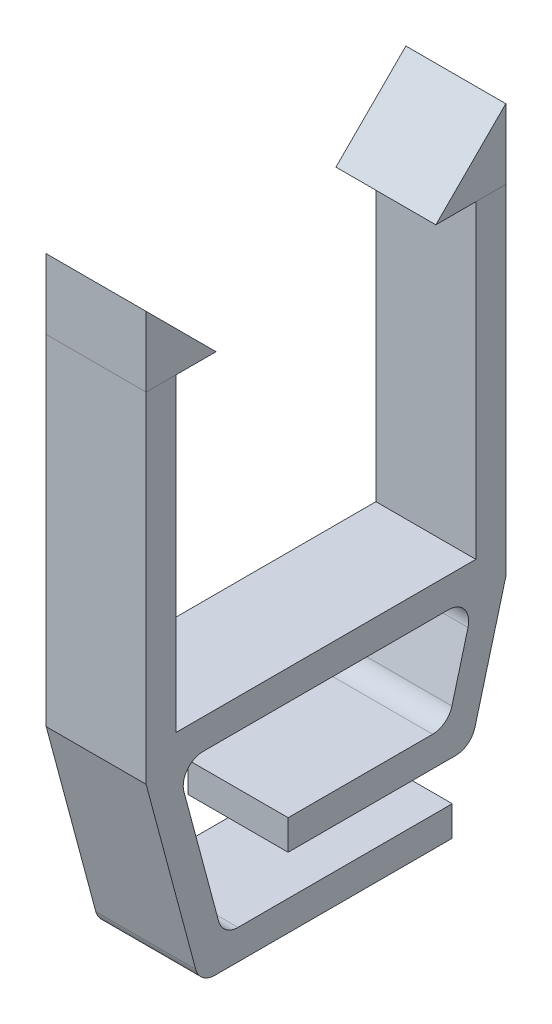
from build123d import *

# Parameters (mm, degrees)
SKETCH_1_W        = 5
SKETCH_1_H        = 1.5
EXTRUDE_1_DEPTH   = 15.5
EXTRUDE_1_2_DEPTH = 15.5
SKETCH_2_W        = 5
SKETCH_2_H        = 18
EXTRUDE_2_DEPTH   = 1.5
EXTRUDE_3_DEPTH   = 5
EXTRUDE_3_2_DEPTH = 5
EXTRUDE_4_DEPTH   = 5
FILLET_1_R        = 1


with BuildPart() as part:
    # 草图1 → 凸台-拉伸1 (new body)
    with BuildSketch(Plane(origin=(0, 0, 0), x_dir=(1, 0, 0), z_dir=(0, 1, 0))):
        with Locations((-8.475609756, 8.298780488)):
            Rectangle(SKETCH_1_W, SKETCH_1_H)
    extrude(amount=EXTRUDE_1_DEPTH)



with BuildPart() as body_2:
    # 草图1 → Extrude 1 2 (new body)
    with BuildSketch(Plane(origin=(0, 0, 0), x_dir=(1, 0, 0), z_dir=(0, 1, 0))):
        with Locations((-8.475609756, -8.201219512)):
            Rectangle(SKETCH_1_W, SKETCH_1_H)
    extrude(amount=EXTRUDE_1_2_DEPTH)


with BuildPart() as part_1:
    add(part.part)

    add(body_2.part)  # 凸台-拉伸2 merges body 2
    # 草图2 → 凸台-拉伸2 (add)
    with BuildSketch(Plane.XZ):
        with Locations((-8.475609756, -0.048780488)):
            Rectangle(SKETCH_2_W, SKETCH_2_H)
    extrude(amount=EXTRUDE_2_DEPTH)

    # 草图4 → 凸台-拉伸4 (add)
    with BuildSketch(Plane(origin=(-5.975609756, 0, 0), x_dir=(0, 0, -1), z_dir=(1, 0, 0))):
        Polygon((-8.951219512, -1.5), (-6.271727588, -11.5), (6.369288563, -11.5), (6.369288563, -10), (-5.120737106, -10), (-7.398305242, -1.5), align=None)
        Polygon((9.048780488, -1.5), (7.307110737, -8), (-1.843879745, -8), (-1.843879745, -6.5), (6.156120255, -6.5), (7.495866217, -1.5), align=None)
    extrude(amount=-EXTRUDE_4_DEPTH)

    # 圆角1
    fillet_1_edges = [part_1.edges().sort_by_distance(p)[0] for p in [
        (-8.475609756, -1.5, 7.398305242),
        (-8.475609756, -10, 5.120737106),
        (-8.475609756, -11.5, 6.271727588),
        (-8.475609756, -1.5, -7.495866217),
        (-8.475609756, -8, -7.307110737),
        (-8.475609756, -6.5, -6.156120255),
    ]]
    fillet(fillet_1_edges, radius=FILLET_1_R)


with BuildPart() as body_2_2:
    # 草图3 → 凸台-拉伸3 (new body)
    with BuildSketch(Plane(origin=(-5.975609756, 0, 0), x_dir=(0, 0, -1), z_dir=(1, 0, 0))):
        Polygon((9.048780488, 15.5), (9.048780488, 19), (5.548780488, 15.5), align=None)
    extrude(amount=-EXTRUDE_3_DEPTH)


with BuildPart() as body_3:
    # 草图3 → Extrude 3 2 (new body)
    with BuildSketch(Plane(origin=(-5.975609756, 0, 0), x_dir=(0, 0, -1), z_dir=(1, 0, 0))):
        Polygon((-8.951219512, 15.5), (-8.951219512, 19), (-5.451219512, 15.5), align=None)
    extrude(amount=-EXTRUDE_3_2_DEPTH)


solid = Compound([part_1.part, body_2_2.part, body_3.part])
